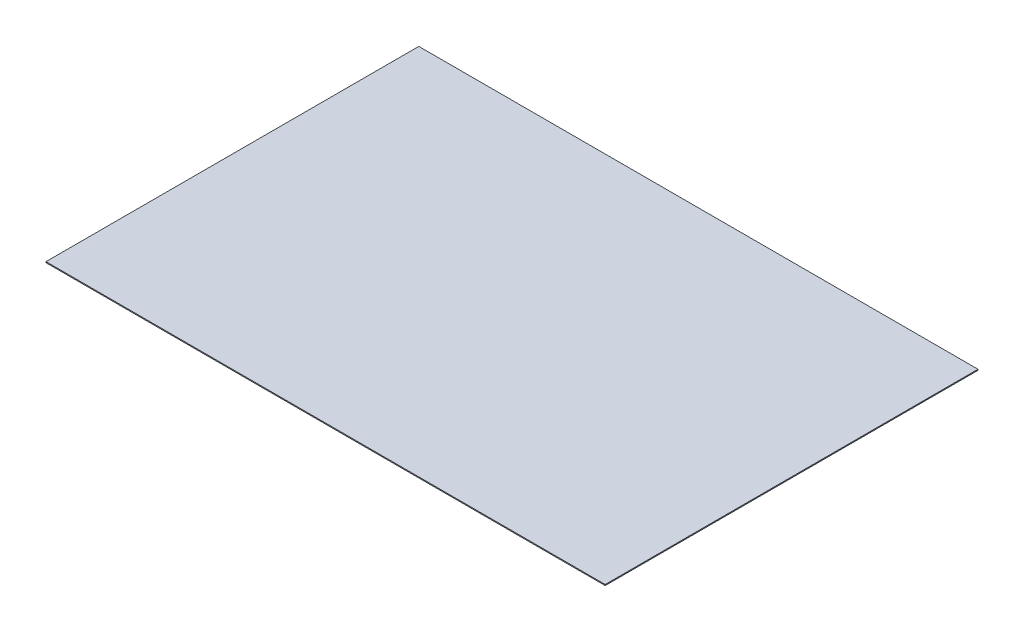
from build123d import *

# Parameters (mm, degrees)
SKETCH1_W           = 3657.6
SKETCH1_H           = 2438.4
BOSS_EXTRUDE1_DEPTH = 6.35


with BuildPart() as part:
    # Sketch1 → Boss-Extrude1 (new body)
    with BuildSketch(Plane(origin=(0, 0, 0), x_dir=(1, 0, 0), z_dir=(0, 1, 0))):
        with Locations((1828.8, 1219.2)):
            Rectangle(SKETCH1_W, SKETCH1_H)
    extrude(amount=BOSS_EXTRUDE1_DEPTH)


solid = part.part
